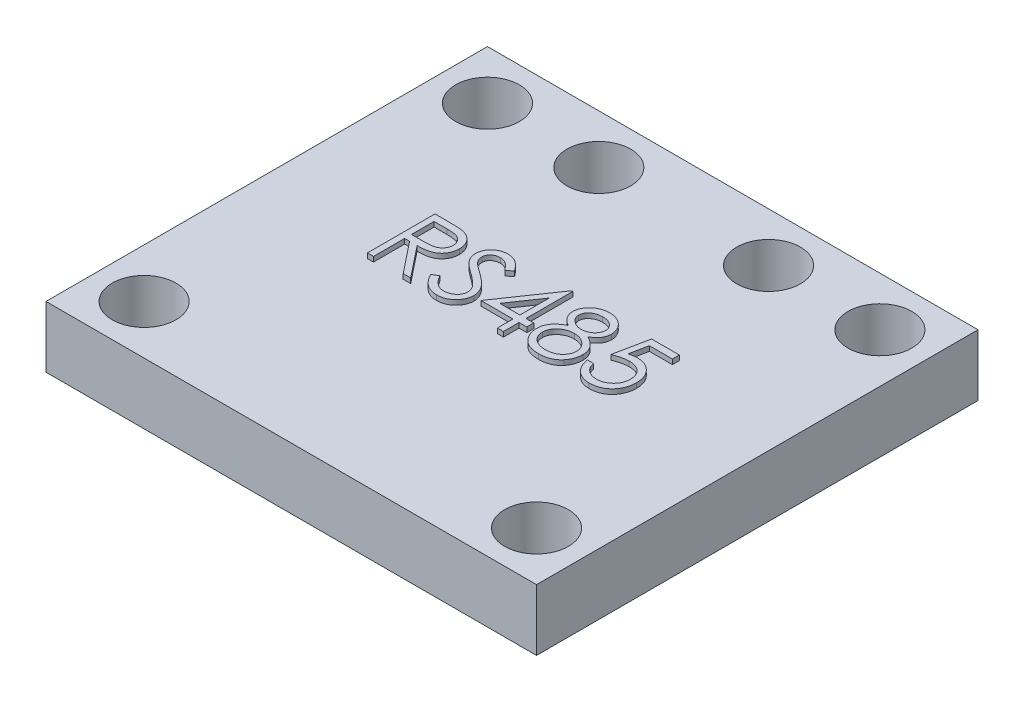
from build123d import *

# Parameters (mm, degrees)
SKETCH2_W           = 25.4
SKETCH2_H           = 22.86
SKETCH2_R           = 1.651
BOSS_EXTRUDE1_DEPTH = 3.175
BOSS_EXTRUDE2_DEPTH = 0.254


with BuildPart() as part:
    # Sketch2 → Boss-Extrude1 (new body)
    with BuildSketch(Plane(origin=(0, 0, 0), x_dir=(1, 0, 0), z_dir=(0, 1, 0))):
        Rectangle(SKETCH2_W, SKETCH2_H)
        with Locations((-10.16, 8.89)):
            Circle(SKETCH2_R, mode=Mode.SUBTRACT)
        with Locations((10.16, 8.89)):
            Circle(SKETCH2_R, mode=Mode.SUBTRACT)
        with Locations((10.16, -8.89)):
            Circle(SKETCH2_R, mode=Mode.SUBTRACT)
        with Locations((-10.16, -8.89)):
            Circle(SKETCH2_R, mode=Mode.SUBTRACT)
        with Locations((-4.3942, 8.89)):
            Circle(SKETCH2_R, mode=Mode.SUBTRACT)
        with Locations((4.3942, 8.89)):
            Circle(SKETCH2_R, mode=Mode.SUBTRACT)
    extrude(amount=-BOSS_EXTRUDE1_DEPTH)

    # Sketch3 → Boss-Extrude2 (add)
    with BuildSketch(Plane(origin=(0, 0, 0), x_dir=(1, 0, 0), z_dir=(0, 1, 0))):
        with BuildLine():
            Line((-6.300240695, 2.311739831), (-5.599820022, 2.311739831))
            add(Edge.make_bspline(
                [(-5.599820022, 2.311739831), (-5.553078893, 2.311584245), (-5.463330749, 2.311285503), (-5.334757478, 2.30961974), (-5.217930381, 2.304845384), (-5.112910542, 2.3007368), (-5.019699887, 2.293244859), (-4.938012596, 2.286084212), (-4.868224899, 2.276710551), (-4.825979047, 2.268005128), (-4.806851272, 2.264063549)],
                knots=[0, 0, 0, 0, 0.000140226, 0.00026925, 0.000385712, 0.000490995, 0.000584507, 0.000666202, 0.000736998, 0.000795574, 0.000795574, 0.000795574, 0.000795574], degree=3))
            add(Edge.make_bspline(
                [(-4.806851272, 2.264063549), (-4.781244647, 2.257736783), (-4.730577658, 2.24521822), (-4.657627592, 2.218758619), (-4.588113268, 2.188138994), (-4.522323444, 2.152175274), (-4.460587652, 2.110600494), (-4.402269342, 2.064132372), (-4.347103878, 2.013025166), (-4.297322248, 1.955990325), (-4.250383196, 1.896153815), (-4.21079457, 1.831450058), (-4.17666809, 1.763788531), (-4.149497573, 1.692481113), (-4.1276196, 1.618219341), (-4.11219336, 1.540330544), (-4.102942173, 1.459169569), (-4.102000317, 1.40381166), (-4.101522746, 1.375742235)],
                knots=[0, 0, 0, 0, 7.9081e-05, 0.000156475, 0.000232432, 0.000306798, 0.00038108, 0.000455429, 0.000530331, 0.000606314, 0.000682321, 0.000758201, 0.000833453, 0.000909362, 0.000986794, 0.001065445, 0.001147284, 0.001231465, 0.001231465, 0.001231465, 0.001231465], degree=3))
            add(Edge.make_bspline(
                [(-4.101522746, 1.375742235), (-4.102991744, 1.32910713), (-4.10585814, 1.238109962), (-4.132583243, 1.106049081), (-4.176359763, 0.982859766), (-4.236683052, 0.868697128), (-4.313502528, 0.765786483), (-4.405827319, 0.675396028), (-4.513708931, 0.599756115), (-4.614138246, 0.54730331), (-4.702852446, 0.513710402), (-4.775885759, 0.490074043), (-4.855552736, 0.471812078), (-4.941090071, 0.455451946), (-5.032853727, 0.443100251), (-5.130623766, 0.434053657), (-5.234469918, 0.428399608), (-5.305808987, 0.427557603), (-5.342508323, 0.427124446)],
                knots=[0, 0, 0, 0, 0.000139777, 0.000272741, 0.000402249, 0.000530843, 0.000658588, 0.000786009, 0.000916741, 0.001052522, 0.001124656, 0.001201155, 0.001282612, 0.001369656, 0.001462366, 0.001560247, 0.001664165, 0.001774261, 0.001774261, 0.001774261, 0.001774261], degree=3))
            Line((-5.342508323, 0.427124446), (-4.056650951, -1.188260169))
            Line((-4.056650951, -1.188260169), (-4.445072425, -1.188260169))
            Line((-4.445072425, -1.188260169), (-5.730929797, 0.427124446))
            Line((-5.730929797, 0.427124446), (-5.986138131, 0.427124446))
            Line((-5.986138131, 0.427124446), (-5.986138131, -1.188260169))
            Line((-5.986138131, -1.188260169), (-6.300240695, -1.188260169))
            Line((-6.300240695, -1.188260169), (-6.300240695, 2.311739831))
        make_face()
        with BuildLine():
            Line((-5.986138131, 1.952765472), (-5.986138131, 0.786098805))
            Line((-5.986138131, 0.786098805), (-5.34531281, 0.781190953))
            add(Edge.make_bspline(
                [(-5.34531281, 0.781190953), (-5.315392771, 0.781177716), (-5.257399214, 0.78115206), (-5.173498549, 0.785145836), (-5.095378437, 0.789689154), (-5.023337685, 0.7966385), (-4.95734411, 0.805594571), (-4.897430697, 0.816797556), (-4.843499645, 0.829849618), (-4.780601106, 0.850051244), (-4.710364575, 0.882057262), (-4.634033115, 0.928622761), (-4.569030777, 0.98719188), (-4.514112915, 1.054165336), (-4.469983484, 1.127801585), (-4.438871429, 1.207217954), (-4.419128987, 1.290409552), (-4.416800442, 1.34758766), (-4.41562531, 1.376443357)],
                knots=[0, 0, 0, 0, 8.9746e-05, 0.000173954, 0.000251933, 0.000324488, 0.000391021, 0.000451663, 0.000507268, 0.000557378, 0.000649639, 0.000738152, 0.000824558, 0.000910739, 0.000997194, 0.001080909, 0.00116578, 0.001252248, 0.001252248, 0.001252248, 0.001252248], degree=3))
            add(Edge.make_bspline(
                [(-4.41562531, 1.376443357), (-4.416827431, 1.40458993), (-4.419209596, 1.460366169), (-4.438658365, 1.542022079), (-4.471547746, 1.619089029), (-4.515869984, 1.691253514), (-4.569869139, 1.75675925), (-4.633186952, 1.812806403), (-4.704092147, 1.859055868), (-4.770363345, 1.888610248), (-4.829597558, 1.906730102), (-4.881027218, 1.919481265), (-4.939138696, 1.929725734), (-5.004214154, 1.937933795), (-5.075975785, 1.94498874), (-5.154786436, 1.949740518), (-5.240123216, 1.952554382), (-5.299270148, 1.952693471), (-5.329888131, 1.952765472)],
                knots=[0, 0, 0, 0, 8.4371e-05, 0.000167192, 0.000250141, 0.000334794, 0.000420435, 0.000503871, 0.000587493, 0.000673488, 0.0007205, 0.000773215, 0.000832351, 0.0008974, 0.000969955, 0.001048634, 0.001134217, 0.001226067, 0.001226067, 0.001226067, 0.001226067], degree=3))
            Line((-5.329888131, 1.952765472), (-5.986138131, 1.952765472))
        make_face(mode=Mode.SUBTRACT)
        with BuildLine():
            Line((-3.697676592, -0.513079881), (-3.401803195, -0.335696067))
            add(Edge.make_bspline(
                [(-3.401803195, -0.335696067), (-3.374284957, -0.381760452), (-3.321561077, -0.470018035), (-3.233609718, -0.589276076), (-3.142476806, -0.690638233), (-3.047487473, -0.77351484), (-2.949221525, -0.838763727), (-2.847037471, -0.884965959), (-2.74127966, -0.913781934), (-2.669305839, -0.917282021), (-2.633373707, -0.9190294)],
                knots=[0, 0, 0, 0, 0.000160901, 0.00030828, 0.000443778, 0.00056903, 0.000685513, 0.000796284, 0.00090427, 0.001011928, 0.001011928, 0.001011928, 0.001011928], degree=3))
            add(Edge.make_bspline(
                [(-2.633373707, -0.9190294), (-2.602686847, -0.918174727), (-2.541850074, -0.916480337), (-2.452287831, -0.900199535), (-2.365306029, -0.875187406), (-2.282697391, -0.839366475), (-2.205601776, -0.796027989), (-2.137995081, -0.743681811), (-2.079548968, -0.685075606), (-2.031739853, -0.619692951), (-1.995059818, -0.549375802), (-1.96686775, -0.477199851), (-1.951222676, -0.402031283), (-1.948865922, -0.35142082), (-1.947676592, -0.325880361)],
                knots=[0, 0, 0, 0, 9.1978e-05, 0.000182347, 0.000272202, 0.000362975, 0.000451852, 0.000536835, 0.000618639, 0.000699414, 0.000778765, 0.000855983, 0.0009312, 0.001007828, 0.001007828, 0.001007828, 0.001007828], degree=3))
            add(Edge.make_bspline(
                [(-1.947676592, -0.325880361), (-1.949150903, -0.296739512), (-1.952147961, -0.237500423), (-1.977479441, -0.15010077), (-2.017328688, -0.0636082), (-2.054091332, -0.010106934), (-2.073177393, 0.017669318)],
                knots=[0, 0, 0, 0, 8.7281e-05, 0.000177429, 0.000270909, 0.000371844, 0.000371844, 0.000371844, 0.000371844], degree=3))
            add(Edge.make_bspline(
                [(-2.073177393, 0.017669318), (-2.088848008, 0.037716142), (-2.121746502, 0.07980194), (-2.178304014, 0.142447176), (-2.244670129, 0.207065595), (-2.318573684, 0.276124652), (-2.402706772, 0.346412448), (-2.494434287, 0.421280726), (-2.596098146, 0.497882303), (-2.667397642, 0.549254869), (-2.704187009, 0.575762267)],
                knots=[0, 0, 0, 0, 7.6319e-05, 0.000160223, 0.000252933, 0.000354147, 0.000463581, 0.000581729, 0.000709336, 0.000845369, 0.000845369, 0.000845369, 0.000845369], degree=3))
            add(Edge.make_bspline(
                [(-2.704187009, 0.575762267), (-2.741011005, 0.601990854), (-2.811415681, 0.652137917), (-2.909874264, 0.726562201), (-2.997918727, 0.79460607), (-3.075157743, 0.856910082), (-3.14155734, 0.913482687), (-3.197640751, 0.963780626), (-3.241979308, 1.009164187), (-3.266634889, 1.038605529), (-3.277704637, 1.051823965)],
                knots=[0, 0, 0, 0, 0.000135623, 0.000259301, 0.000370234, 0.000469439, 0.00055697, 0.000631911, 0.000695377, 0.00074709, 0.00074709, 0.00074709, 0.00074709], degree=3))
            add(Edge.make_bspline(
                [(-3.277704637, 1.051823965), (-3.293177182, 1.072425002), (-3.323606019, 1.112939706), (-3.363772024, 1.176264564), (-3.397911187, 1.241087829), (-3.424673519, 1.307583694), (-3.447209738, 1.374818623), (-3.462367669, 1.443669868), (-3.471859066, 1.513828487), (-3.472831052, 1.561041988), (-3.473317618, 1.58467653)],
                knots=[0, 0, 0, 0, 7.727e-05, 0.000151962, 0.000224716, 0.000296717, 0.00036678, 0.0004372, 0.000507902, 0.000578771, 0.000578771, 0.000578771, 0.000578771], degree=3))
            add(Edge.make_bspline(
                [(-3.473317618, 1.58467653), (-3.472012409, 1.621706304), (-3.469429889, 1.694974368), (-3.447589371, 1.802005198), (-3.413116478, 1.904191616), (-3.36482159, 2.000521949), (-3.302564237, 2.08848793), (-3.230518263, 2.169101417), (-3.144706776, 2.236869999), (-3.050554153, 2.296082058), (-2.947497781, 2.342427983), (-2.839506878, 2.377388963), (-2.726409806, 2.397198221), (-2.649806671, 2.400040986), (-2.61093781, 2.401483421)],
                knots=[0, 0, 0, 0, 0.000110999, 0.000219625, 0.000326272, 0.00043382, 0.000541574, 0.000648775, 0.000756959, 0.000868438, 0.000981703, 0.00109501, 0.001208203, 0.0013248, 0.0013248, 0.0013248, 0.0013248], degree=3))
            add(Edge.make_bspline(
                [(-2.61093781, 2.401483421), (-2.56969371, 2.400060869), (-2.487672358, 2.397231868), (-2.367023142, 2.372634337), (-2.250862426, 2.331933665), (-2.157419161, 2.285745007), (-2.0842864, 2.239613591), (-2.028513667, 2.197593767), (-1.971996216, 2.149218658), (-1.914278161, 2.094359412), (-1.856337502, 2.032512661), (-1.79731405, 1.964101972), (-1.737069781, 1.889545416), (-1.698313921, 1.836320916), (-1.678445823, 1.809035504)],
                knots=[0, 0, 0, 0, 0.000123638, 0.000245877, 0.000367608, 0.000492088, 0.000557638, 0.000626769, 0.000701372, 0.00078072, 0.000865532, 0.000955497, 0.001051745, 0.001152989, 0.001152989, 0.001152989, 0.001152989], degree=3))
            Line((-1.678445823, 1.809035504), (-1.96240015, 1.593791113))
            add(Edge.make_bspline(
                [(-1.96240015, 1.593791113), (-1.979546082, 1.615879803), (-2.012565139, 1.658417457), (-2.062694626, 1.717988772), (-2.109943274, 1.772405252), (-2.156493674, 1.81967038), (-2.199887305, 1.862372513), (-2.242004348, 1.89893227), (-2.282238699, 1.929707865), (-2.332955609, 1.962551425), (-2.396673328, 1.995107929), (-2.476657864, 2.022657007), (-2.560244139, 2.039212069), (-2.617173771, 2.041400956), (-2.6459939, 2.042509062)],
                knots=[0, 0, 0, 0, 8.3877e-05, 0.000161528, 0.000233552, 0.000299993, 0.000360485, 0.000416152, 0.000467195, 0.000512312, 0.000597287, 0.000681099, 0.000765389, 0.000851809, 0.000851809, 0.000851809, 0.000851809], degree=3))
            add(Edge.make_bspline(
                [(-2.6459939, 2.042509062), (-2.682150422, 2.041297362), (-2.75187487, 2.038960712), (-2.850865106, 2.013440727), (-2.939959031, 1.973258867), (-3.016511596, 1.916943889), (-3.080248573, 1.850222896), (-3.126354032, 1.773444041), (-3.154104196, 1.688661638), (-3.157490476, 1.629519982), (-3.159215054, 1.599400087)],
                knots=[0, 0, 0, 0, 0.000108248, 0.000208746, 0.00030443, 0.000399793, 0.000492054, 0.00057947, 0.000666386, 0.000756591, 0.000756591, 0.000756591, 0.000756591], degree=3))
            add(Edge.make_bspline(
                [(-3.159215054, 1.599400087), (-3.158821927, 1.580648609), (-3.158035031, 1.543114989), (-3.147060233, 1.487663567), (-3.132960904, 1.432352228), (-3.110618272, 1.377429645), (-3.079772969, 1.321935286), (-3.039267793, 1.264913548), (-2.988254481, 1.20586184), (-2.949177469, 1.167454466), (-2.928545983, 1.14717653)],
                knots=[0, 0, 0, 0, 5.616e-05, 0.000112411, 0.000169046, 0.000227244, 0.000289691, 0.000359134, 0.000436702, 0.000523463, 0.000523463, 0.000523463, 0.000523463], degree=3))
            add(Edge.make_bspline(
                [(-2.928545983, 1.14717653), (-2.920884611, 1.140339504), (-2.902682944, 1.124096295), (-2.869407018, 1.097504015), (-2.82546422, 1.064701243), (-2.772002018, 1.024113926), (-2.708034657, 0.977032464), (-2.633555101, 0.924058852), (-2.549393568, 0.863473393), (-2.489671652, 0.821115852), (-2.458093259, 0.798718998)],
                knots=[0, 0, 0, 0, 3.0802e-05, 7.3177e-05, 0.000127725, 0.000195314, 0.000274544, 0.000365991, 0.000469501, 0.000585644, 0.000585644, 0.000585644, 0.000585644], degree=3))
            add(Edge.make_bspline(
                [(-2.458093259, 0.798718998), (-2.420107345, 0.771077638), (-2.346552889, 0.717553976), (-2.241895309, 0.637138296), (-2.147001501, 0.558490528), (-2.061538297, 0.482112921), (-1.984661389, 0.408584828), (-1.917223668, 0.337021647), (-1.858537988, 0.267936075), (-1.79535877, 0.179363499), (-1.73080095, 0.070582415), (-1.675359443, -0.062695824), (-1.640401095, -0.196492144), (-1.63582958, -0.286418981), (-1.633574028, -0.330788214)],
                knots=[0, 0, 0, 0, 0.000140932, 0.000272896, 0.000395881, 0.000510584, 0.000616697, 0.000714904, 0.000805482, 0.000888372, 0.001041088, 0.001183793, 0.001320341, 0.001453327, 0.001453327, 0.001453327, 0.001453327], degree=3))
            add(Edge.make_bspline(
                [(-1.633574028, -0.330788214), (-1.634231166, -0.362166579), (-1.635532681, -0.424313963), (-1.650493595, -0.51556904), (-1.67241326, -0.604199909), (-1.705450494, -0.689111022), (-1.745773652, -0.771855784), (-1.7969399, -0.850263685), (-1.856247585, -0.926070083), (-1.92428135, -0.997253575), (-1.998727252, -1.062599771), (-2.077410947, -1.120728832), (-2.16046122, -1.169197156), (-2.247427536, -1.208747998), (-2.338329873, -1.239681515), (-2.433137657, -1.262094384), (-2.532007168, -1.275850095), (-2.59920765, -1.277277857), (-2.633373707, -1.278003759)],
                knots=[0, 0, 0, 0, 9.4044e-05, 0.000186263, 0.000276729, 0.000367488, 0.000459046, 0.000552398, 0.000647774, 0.000747454, 0.000847311, 0.000944634, 0.001040472, 0.001135227, 0.001230788, 0.001328063, 0.00142712, 0.00152957, 0.00152957, 0.00152957, 0.00152957], degree=3))
            add(Edge.make_bspline(
                [(-2.633373707, -1.278003759), (-2.65980905, -1.277492577), (-2.71234681, -1.276476652), (-2.790056292, -1.267495371), (-2.866195882, -1.254788268), (-2.939810164, -1.234614198), (-3.011847575, -1.210137221), (-3.08199481, -1.179998888), (-3.150285864, -1.143881687), (-3.217103446, -1.102586662), (-3.282277621, -1.054528918), (-3.345197089, -0.998555421), (-3.407926274, -0.936209916), (-3.468613671, -0.865799353), (-3.528486815, -0.78846127), (-3.586365225, -0.703472087), (-3.643446942, -0.611294733), (-3.67926241, -0.546429647), (-3.697676592, -0.513079881)],
                knots=[0, 0, 0, 0, 7.9276e-05, 0.000157554, 0.000234438, 0.000310629, 0.000386236, 0.000462555, 0.000539392, 0.000617798, 0.000698008, 0.000781971, 0.000870217, 0.00096315, 0.001060616, 0.001163492, 0.001271478, 0.00138575, 0.00138575, 0.00138575, 0.00138575], degree=3))
        make_face()
        Polygon((0.680829017, 2.401483421), (0.7446311, 2.401483421), (0.7446311, -0.021593502), (1.148477254, -0.021593502), (1.148477254, -0.380567861), (0.7446311, -0.380567861), (0.7446311, -1.188260169), (0.430528536, -1.188260169), (0.430528536, -0.380567861), (-1.229727874, -0.380567861), align=None)
        Polygon((0.430528536, -0.021593502), (0.430528536, 1.498438549), (-0.612740695, -0.021593502), align=None, mode=Mode.SUBTRACT)
        with BuildLine():
            add(Edge.make_bspline(
                [(3.164202414, 0.761559542), (3.192850962, 0.746621586), (3.248725196, 0.717487584), (3.328302404, 0.670576756), (3.401027406, 0.621135791), (3.468917967, 0.571499932), (3.530781318, 0.51976828), (3.585925731, 0.465735124), (3.635713351, 0.410749179), (3.679140135, 0.353879339), (3.717336972, 0.295276689), (3.750349107, 0.234787416), (3.77856631, 0.172544083), (3.800929248, 0.107867253), (3.81935104, 0.041706991), (3.832026645, -0.026790991), (3.838843563, -0.097175332), (3.840132376, -0.144743633), (3.840784946, -0.168829079)],
                knots=[0, 0, 0, 0, 9.692e-05, 0.000189026, 0.000276921, 0.000360637, 0.000441251, 0.000518597, 0.000592078, 0.000663595, 0.000733021, 0.000801734, 0.000870147, 0.000937778, 0.001006834, 0.001076004, 0.001146466, 0.001218736, 0.001218736, 0.001218736, 0.001218736], degree=3))
            add(Edge.make_bspline(
                [(3.840784946, -0.168829079), (3.840013526, -0.202526812), (3.838486595, -0.269227269), (3.825186611, -0.36767338), (3.805273633, -0.463285162), (3.77619412, -0.556041653), (3.73848073, -0.645431026), (3.692003894, -0.7315298), (3.639392688, -0.815749109), (3.597140449, -0.867568511), (3.575760908, -0.893789015)],
                knots=[0, 0, 0, 0, 0.000101049, 0.000200014, 0.00029751, 0.000393751, 0.000491154, 0.000588073, 0.000687071, 0.000788472, 0.000788472, 0.000788472, 0.000788472], degree=3))
            add(Edge.make_bspline(
                [(3.575760908, -0.893789015), (3.547924434, -0.924382789), (3.492595468, -0.985192282), (3.39781254, -1.064143092), (3.293790657, -1.130492486), (3.180932324, -1.184564381), (3.059539223, -1.22665024), (2.929637218, -1.256892758), (2.790973065, -1.274215187), (2.695667594, -1.276719176), (2.64677453, -1.278003759)],
                knots=[0, 0, 0, 0, 0.000123978, 0.000246423, 0.000368759, 0.000493253, 0.000620972, 0.000753455, 0.000892683, 0.001039354, 0.001039354, 0.001039354, 0.001039354], degree=3))
            add(Edge.make_bspline(
                [(2.64677453, -1.278003759), (2.599761141, -1.276851281), (2.508277862, -1.274608676), (2.375119985, -1.259414244), (2.250996915, -1.232786378), (2.135186946, -1.196341768), (2.028388253, -1.14893154), (1.930905152, -1.089923131), (1.84133118, -1.021691689), (1.762384706, -0.942277611), (1.692296262, -0.857219739), (1.630728209, -0.769468129), (1.579554131, -0.679014771), (1.536227035, -0.587208404), (1.503059013, -0.49276225), (1.480086802, -0.396162237), (1.465497488, -0.297577094), (1.463556353, -0.231045441), (1.462579818, -0.197575073)],
                knots=[0, 0, 0, 0, 0.000141037, 0.000274444, 0.00040137, 0.000521327, 0.000638076, 0.000750983, 0.00086247, 0.000975011, 0.001086056, 0.001192834, 0.001296147, 0.001397463, 0.001497025, 0.001595826, 0.001694979, 0.00179536, 0.00179536, 0.00179536, 0.00179536], degree=3))
            add(Edge.make_bspline(
                [(1.462579818, -0.197575073), (1.463157699, -0.173015881), (1.464299796, -0.124478249), (1.472204644, -0.052768921), (1.484913106, 0.017027214), (1.502172562, 0.085167958), (1.525563589, 0.15115723), (1.553805722, 0.215307704), (1.586737675, 0.277691803), (1.62481884, 0.338650684), (1.669120864, 0.397330196), (1.719284513, 0.454726191), (1.776312382, 0.509948058), (1.839570041, 0.563670483), (1.90833458, 0.616846457), (1.984392111, 0.666602185), (2.065726379, 0.71646015), (2.123531784, 0.746268475), (2.153184786, 0.761559542)],
                knots=[0, 0, 0, 0, 7.3671e-05, 0.0001456, 0.000216149, 0.000286381, 0.000356229, 0.000425923, 0.00049649, 0.000567687, 0.000641305, 0.000716824, 0.000796154, 0.000879197, 0.00096572, 0.001056725, 0.001151716, 0.001251771, 0.001251771, 0.001251771, 0.001251771], degree=3))
            add(Edge.make_bspline(
                [(2.153184786, 0.761559542), (2.112593411, 0.783694311), (2.033997149, 0.826553419), (1.929927707, 0.905300225), (1.840537084, 0.990588039), (1.768282366, 1.084217834), (1.711410138, 1.183264709), (1.672391534, 1.287108961), (1.64599505, 1.393825075), (1.643380223, 1.466731271), (1.642066998, 1.503346401)],
                knots=[0, 0, 0, 0, 0.000138535, 0.000268243, 0.000390218, 0.00050816, 0.000621822, 0.000731457, 0.000840134, 0.00094978, 0.00094978, 0.00094978, 0.00094978], degree=3))
            add(Edge.make_bspline(
                [(1.642066998, 1.503346401), (1.643702422, 1.54064396), (1.646989909, 1.615618557), (1.67357323, 1.72722468), (1.716893297, 1.836841245), (1.775814294, 1.943936958), (1.84920151, 2.044887172), (1.937248056, 2.135428119), (2.037851352, 2.214739601), (2.150509219, 2.281315774), (2.271745455, 2.335499433), (2.399661179, 2.372877856), (2.532027672, 2.397313972), (2.622125391, 2.400080627), (2.667808184, 2.401483421)],
                knots=[0, 0, 0, 0, 0.000111795, 0.000224728, 0.000342168, 0.000464543, 0.000590474, 0.000715423, 0.000842224, 0.000973648, 0.001107055, 0.001239485, 0.001372621, 0.001509557, 0.001509557, 0.001509557, 0.001509557], degree=3))
            add(Edge.make_bspline(
                [(2.667808184, 2.401483421), (2.712311999, 2.400037078), (2.800068452, 2.397185054), (2.929063079, 2.373398176), (3.052487957, 2.333668656), (3.169917456, 2.279771433), (3.279249323, 2.213384492), (3.375851632, 2.132983618), (3.461184214, 2.042842067), (3.531768609, 1.941922464), (3.589931498, 1.83523827), (3.630432399, 1.723615749), (3.656384373, 1.60946669), (3.659657737, 1.532228686), (3.661297767, 1.493530696)],
                knots=[0, 0, 0, 0, 0.000133436, 0.000263121, 0.000391946, 0.000521517, 0.000649943, 0.000774455, 0.000897469, 0.001021193, 0.0011429, 0.001260905, 0.001376422, 0.001492413, 0.001492413, 0.001492413, 0.001492413], degree=3))
            add(Edge.make_bspline(
                [(3.661297767, 1.493530696), (3.659863206, 1.455554032), (3.657045811, 1.380970023), (3.633345871, 1.272243503), (3.593432558, 1.170421464), (3.538938395, 1.074348511), (3.467912907, 0.985767014), (3.381304174, 0.903550544), (3.279802696, 0.827023716), (3.20354181, 0.783837351), (3.164202414, 0.761559542)],
                knots=[0, 0, 0, 0, 0.000113843, 0.000223582, 0.000331909, 0.000440874, 0.000553657, 0.00067118, 0.000798364, 0.000933876, 0.000933876, 0.000933876, 0.000933876], degree=3))
        make_face()
        with BuildLine():
            add(Edge.make_bspline(
                [(2.650280139, 2.042509062), (2.625729333, 2.041857621), (2.577697222, 2.040583119), (2.507268551, 2.033924482), (2.440296183, 2.020971265), (2.376080383, 2.003732553), (2.31550157, 1.980444565), (2.257737016, 1.953049556), (2.203769826, 1.91974349), (2.152948523, 1.882382292), (2.107197749, 1.841289386), (2.066593197, 1.798475668), (2.032865083, 1.753100275), (2.004223973, 1.706291916), (1.983442456, 1.656661339), (1.967878152, 1.605730163), (1.95735676, 1.552854779), (1.95656837, 1.516718268), (1.956169562, 1.498438549)],
                knots=[0, 0, 0, 0, 7.3671e-05, 0.000144133, 0.000211925, 0.000278091, 0.000343329, 0.00040636, 0.000469609, 0.000533272, 0.00059534, 0.000653874, 0.000709964, 0.000764674, 0.00081807, 0.000870854, 0.000924347, 0.000979106, 0.000979106, 0.000979106, 0.000979106], degree=3))
            add(Edge.make_bspline(
                [(1.956169562, 1.498438549), (1.956856929, 1.480158039), (1.958215264, 1.444033126), (1.968720392, 1.39068726), (1.984377247, 1.338265624), (2.009027909, 1.288014713), (2.038594267, 1.238191353), (2.075085743, 1.190040767), (2.118574771, 1.143395382), (2.167602211, 1.098651941), (2.221013749, 1.056753178), (2.277597792, 1.020379997), (2.336644184, 0.989945886), (2.397546253, 0.964616481), (2.4609247, 0.944926544), (2.526391174, 0.930957898), (2.593956676, 0.922275901), (2.639737257, 0.92123888), (2.662900331, 0.92071419)],
                knots=[0, 0, 0, 0, 5.48e-05, 0.000108292, 0.000162623, 0.00021845, 0.000275685, 0.000336262, 0.000399273, 0.000466763, 0.000535204, 0.00060269, 0.000668229, 0.000734243, 0.000800327, 0.000867022, 0.000934854, 0.001004321, 0.001004321, 0.001004321, 0.001004321], degree=3))
            add(Edge.make_bspline(
                [(2.662900331, 0.92071419), (2.692650435, 0.921587057), (2.751856802, 0.92332417), (2.839136134, 0.939475344), (2.923998778, 0.964881261), (3.005537683, 0.999641228), (3.081642268, 1.043269088), (3.149482336, 1.095502106), (3.208479229, 1.155134203), (3.258019839, 1.221237039), (3.296429686, 1.291588627), (3.326331494, 1.36218892), (3.343792709, 1.433791151), (3.346070276, 1.481758115), (3.347195203, 1.505449767)],
                knots=[0, 0, 0, 0, 8.9178e-05, 0.000177474, 0.000265314, 0.000354521, 0.00044279, 0.000527774, 0.000610569, 0.000693722, 0.000774691, 0.000850468, 0.000923253, 0.000994288, 0.000994288, 0.000994288, 0.000994288], degree=3))
            add(Edge.make_bspline(
                [(3.347195203, 1.505449767), (3.346663305, 1.522077803), (3.345607565, 1.555082071), (3.336907509, 1.603820436), (3.322531676, 1.651450019), (3.303068596, 1.69836429), (3.277458801, 1.743905022), (3.247094614, 1.78878811), (3.210210112, 1.832003874), (3.168813679, 1.874559423), (3.12186827, 1.913943446), (3.069464358, 1.948578157), (3.011870607, 1.977990513), (2.949085657, 2.001879268), (2.881340733, 2.019821617), (2.808947859, 2.033257965), (2.731303412, 2.040831077), (2.677873661, 2.041937602), (2.650280139, 2.042509062)],
                knots=[0, 0, 0, 0, 4.9859e-05, 9.8962e-05, 0.000147986, 0.000198898, 0.000250994, 0.000304472, 0.000361207, 0.000421197, 0.00048242, 0.000544646, 0.00060924, 0.000676039, 0.000745771, 0.000819205, 0.000896713, 0.000979493, 0.000979493, 0.000979493, 0.000979493], degree=3))
        make_face(mode=Mode.SUBTRACT)
        with BuildLine():
            add(Edge.make_bspline(
                [(2.670612671, 0.561739831), (2.639486885, 0.56118619), (2.578425689, 0.56010008), (2.488968761, 0.54801058), (2.403115595, 0.531181187), (2.321155659, 0.505650348), (2.243123562, 0.472453858), (2.168596879, 0.432519318), (2.09814575, 0.385313875), (2.032743023, 0.331437259), (1.973019694, 0.273377805), (1.920621394, 0.21191567), (1.876123873, 0.148193137), (1.840290623, 0.081400908), (1.81087889, 0.012953297), (1.791565013, -0.058854298), (1.779183302, -0.132641411), (1.77752067, -0.18280151), (1.776682382, -0.2080919)],
                knots=[0, 0, 0, 0, 9.3315e-05, 0.000183061, 0.000270376, 0.000355532, 0.000440046, 0.000524429, 0.000608823, 0.000694017, 0.000778303, 0.000858382, 0.000935982, 0.001010962, 0.001085443, 0.001158927, 0.001233504, 0.001309342, 0.001309342, 0.001309342, 0.001309342], degree=3))
            add(Edge.make_bspline(
                [(1.776682382, -0.2080919), (1.778045641, -0.239522806), (1.780750315, -0.301880989), (1.802206953, -0.394044061), (1.836642489, -0.483265115), (1.884667705, -0.568817068), (1.944135277, -0.648767175), (2.017261745, -0.71845595), (2.099502583, -0.780377429), (2.193640437, -0.830457962), (2.296468903, -0.870452817), (2.407960632, -0.89800878), (2.526515551, -0.91625023), (2.608375143, -0.918088411), (2.650280139, -0.9190294)],
                knots=[0, 0, 0, 0, 9.4212e-05, 0.000186914, 0.000282354, 0.00038028, 0.000480401, 0.000580061, 0.000682286, 0.000788322, 0.000898864, 0.001012456, 0.001132235, 0.001257861, 0.001257861, 0.001257861, 0.001257861], degree=3))
            add(Edge.make_bspline(
                [(2.650280139, -0.9190294), (2.683030507, -0.918400591), (2.746838726, -0.917175471), (2.839924675, -0.906361177), (2.927769223, -0.889211552), (3.010202022, -0.864268006), (3.088145861, -0.83381803), (3.160279215, -0.794645948), (3.228457742, -0.750093625), (3.289321865, -0.697235469), (3.344755074, -0.640755974), (3.393088366, -0.580965931), (3.435045918, -0.519490298), (3.467976873, -0.454939814), (3.494303127, -0.388552899), (3.513226682, -0.319717388), (3.524902897, -0.248222155), (3.526083793, -0.199723084), (3.526682382, -0.175139176)],
                knots=[0, 0, 0, 0, 9.822e-05, 0.000191363, 0.000280739, 0.000366362, 0.000449427, 0.000531293, 0.000612187, 0.000693253, 0.000772583, 0.000849342, 0.000923624, 0.000995434, 0.001066261, 0.001137531, 0.001209227, 0.001282928, 0.001282928, 0.001282928, 0.001282928], degree=3))
            add(Edge.make_bspline(
                [(3.526682382, -0.175139176), (3.525776534, -0.151261835), (3.523990359, -0.10417989), (3.512653667, -0.034413364), (3.49273779, 0.032989451), (3.465410393, 0.098839457), (3.429029431, 0.161802407), (3.386184561, 0.223518579), (3.334490442, 0.282275023), (3.276077846, 0.338528119), (3.212418885, 0.390543856), (3.14475174, 0.436558294), (3.073597278, 0.475310411), (2.999106067, 0.506826906), (2.921443511, 0.531614376), (2.840666733, 0.548930371), (2.756681158, 0.559829974), (2.699626287, 0.56109602), (2.670612671, 0.561739831)],
                knots=[0, 0, 0, 0, 7.1638e-05, 0.000141258, 0.00021137, 0.000282076, 0.000354604, 0.000429101, 0.000507127, 0.000588942, 0.000672164, 0.000753448, 0.00083408, 0.000914819, 0.000995752, 0.001078265, 0.001162358, 0.001249368, 0.001249368, 0.001249368, 0.001249368], degree=3))
        make_face(mode=Mode.SUBTRACT)
        with BuildLine():
            Line((6.353605459, 2.311739831), (6.353605459, 1.952765472))
            Line((6.353605459, 1.952765472), (5.163100652, 1.952765472))
            Line((5.163100652, 1.952765472), (4.974498889, 1.032192555))
            add(Edge.make_bspline(
                [(4.974498889, 1.032192555), (5.011554763, 1.042422827), (5.083344659, 1.062242361), (5.18930452, 1.084248131), (5.289896723, 1.097513575), (5.355172094, 1.099324886), (5.386758504, 1.100201369)],
                knots=[0, 0, 0, 0, 0.000115302, 0.000223379, 0.000324431, 0.000419176, 0.000419176, 0.000419176, 0.000419176], degree=3))
            add(Edge.make_bspline(
                [(5.386758504, 1.100201369), (5.425842244, 1.099355434), (5.502690641, 1.097692113), (5.615129588, 1.081720263), (5.722462481, 1.056580349), (5.824464852, 1.021459827), (5.921325402, 0.976550094), (6.012152964, 0.920450153), (6.098310877, 0.854916822), (6.178253471, 0.77957181), (6.250777779, 0.696650193), (6.314543768, 0.607492322), (6.368706359, 0.51296466), (6.412267114, 0.412164052), (6.447051448, 0.306204898), (6.470203443, 0.193972316), (6.485620152, 0.076524196), (6.487342538, -0.003780374), (6.488220844, -0.044730522)],
                knots=[0, 0, 0, 0, 0.00011719, 0.000230425, 0.000339944, 0.000447481, 0.000553499, 0.000659556, 0.000767111, 0.000877722, 0.000988528, 0.001097091, 0.001206056, 0.001314692, 0.001425996, 0.001539995, 0.001658004, 0.001780798, 0.001780798, 0.001780798, 0.001780798], degree=3))
            add(Edge.make_bspline(
                [(6.488220844, -0.044730522), (6.487555769, -0.073252742), (6.486234606, -0.12991173), (6.479516018, -0.21405593), (6.466580302, -0.296418763), (6.449212578, -0.377011155), (6.42667016, -0.455680527), (6.399381106, -0.532652055), (6.365985079, -0.607446662), (6.329353703, -0.680772057), (6.288107225, -0.750970564), (6.242328718, -0.816619551), (6.193963227, -0.878703832), (6.141921841, -0.936557565), (6.085720846, -0.989800583), (6.026040879, -1.038748865), (5.96335816, -1.084230195), (5.896702918, -1.12439839), (5.827560435, -1.161361346), (5.754932218, -1.191684884), (5.680471518, -1.218795412), (5.603106642, -1.240404939), (5.523012829, -1.257337494), (5.440058054, -1.268838095), (5.354677384, -1.277214532), (5.296802371, -1.277738889), (5.267567799, -1.278003759)],
                knots=[0, 0, 0, 0, 8.5583e-05, 0.000170009, 0.000253005, 0.000335518, 0.000417186, 0.000498352, 0.000580291, 0.000662755, 0.000744161, 0.000824288, 0.000902692, 0.000980133, 0.001057498, 0.001134702, 0.00121156, 0.001289599, 0.001368002, 0.001446531, 0.001525481, 0.001605609, 0.001687289, 0.001770875, 0.001856759, 0.001944425, 0.001944425, 0.001944425, 0.001944425], degree=3))
            add(Edge.make_bspline(
                [(5.267567799, -1.278003759), (5.232693618, -1.277312921), (5.164082788, -1.275953779), (5.06356222, -1.261735294), (4.966847615, -1.241371377), (4.874717514, -1.210735107), (4.78634625, -1.172347813), (4.702923532, -1.123831641), (4.622317756, -1.068852537), (4.547805719, -1.003972184), (4.478649606, -0.933056502), (4.416743097, -0.856098861), (4.36160952, -0.774369419), (4.314131773, -0.687471265), (4.273633752, -0.595632734), (4.241818764, -0.498509733), (4.216140409, -0.396609729), (4.205276988, -0.326456219), (4.199759305, -0.290824272)],
                knots=[0, 0, 0, 0, 0.000104552, 0.000205693, 0.000304023, 0.000400691, 0.00049644, 0.000592535, 0.000689779, 0.000788716, 0.000888377, 0.000986596, 0.001084603, 0.001183757, 0.001283279, 0.001385267, 0.001490017, 0.001598135, 0.001598135, 0.001598135, 0.001598135], degree=3))
            Line((4.199759305, -0.290824272), (4.513861869, -0.290824272))
            add(Edge.make_bspline(
                [(4.513861869, -0.290824272), (4.521590427, -0.324200724), (4.536445143, -0.388352119), (4.569050892, -0.47848346), (4.608916768, -0.558802684), (4.656321116, -0.630372267), (4.712871146, -0.692781265), (4.777400575, -0.748398327), (4.849748299, -0.798573456), (4.930141528, -0.840396223), (5.014954607, -0.876064976), (5.103721817, -0.899816671), (5.194026164, -0.916517564), (5.255104534, -0.918189325), (5.285796966, -0.9190294)],
                knots=[0, 0, 0, 0, 0.000102709, 0.000197412, 0.000286774, 0.000371169, 0.000454082, 0.000538572, 0.000626283, 0.000717552, 0.000809994, 0.00090168, 0.00099274, 0.001084718, 0.001084718, 0.001084718, 0.001084718], degree=3))
            add(Edge.make_bspline(
                [(5.285796966, -0.9190294), (5.31575541, -0.918208622), (5.374743832, -0.916592504), (5.461555219, -0.904153491), (5.545368093, -0.88499592), (5.62535545, -0.856326065), (5.702916989, -0.821481347), (5.77609076, -0.776766271), (5.846993637, -0.725306253), (5.913421771, -0.666349622), (5.97426122, -0.601379928), (6.028017341, -0.531902534), (6.072794254, -0.457785688), (6.110528363, -0.380312535), (6.139181662, -0.298633978), (6.159622643, -0.213132803), (6.171625702, -0.123597822), (6.173276882, -0.062528513), (6.17411828, -0.031409208)],
                knots=[0, 0, 0, 0, 8.9842e-05, 0.0001769, 0.000262612, 0.000347317, 0.000431396, 0.000517249, 0.000604055, 0.000693954, 0.000783242, 0.000870748, 0.000956963, 0.001042571, 0.001128832, 0.00121607, 0.001305907, 0.001399251, 0.001399251, 0.001399251, 0.001399251], degree=3))
            add(Edge.make_bspline(
                [(6.17411828, -0.031409208), (6.1734598, -0.003333456), (6.17217092, 0.051620833), (6.16164035, 0.13202004), (6.143323378, 0.208093082), (6.117899498, 0.280207316), (6.08561999, 0.348430758), (6.046173678, 0.412833818), (5.99882028, 0.472567652), (5.944728391, 0.527660205), (5.88547035, 0.57850508), (5.820026608, 0.621849167), (5.749766681, 0.658313084), (5.675537081, 0.689781083), (5.595572183, 0.712381828), (5.51145555, 0.729349713), (5.422278843, 0.739165076), (5.361308154, 0.740526964), (5.329967639, 0.74122701)],
                knots=[0, 0, 0, 0, 8.4208e-05, 0.000164824, 0.000242709, 0.000318547, 0.000393815, 0.000468731, 0.000544614, 0.00062196, 0.000700062, 0.000778428, 0.000856831, 0.000937299, 0.001019835, 0.001105635, 0.00119452, 0.001288536, 0.001288536, 0.001288536, 0.001288536], degree=3))
            add(Edge.make_bspline(
                [(5.329967639, 0.74122701), (5.30283871, 0.740646419), (5.246824355, 0.739447646), (5.160901528, 0.730621149), (5.070609805, 0.716381855), (4.976295309, 0.696795607), (4.877674801, 0.67116453), (4.7749564, 0.64045003), (4.667924134, 0.603728031), (4.595806409, 0.575995817), (4.558733664, 0.561739831)],
                knots=[0, 0, 0, 0, 8.1378e-05, 0.000168026, 0.000258858, 0.000355524, 0.000456875, 0.000564457, 0.000677092, 0.000796243, 0.000796243, 0.000796243, 0.000796243], degree=3))
            Line((4.558733664, 0.561739831), (4.917708023, 2.311739831))
            Line((4.917708023, 2.311739831), (6.353605459, 2.311739831))
        make_face()
    extrude(amount=BOSS_EXTRUDE2_DEPTH)


solid = part.part
